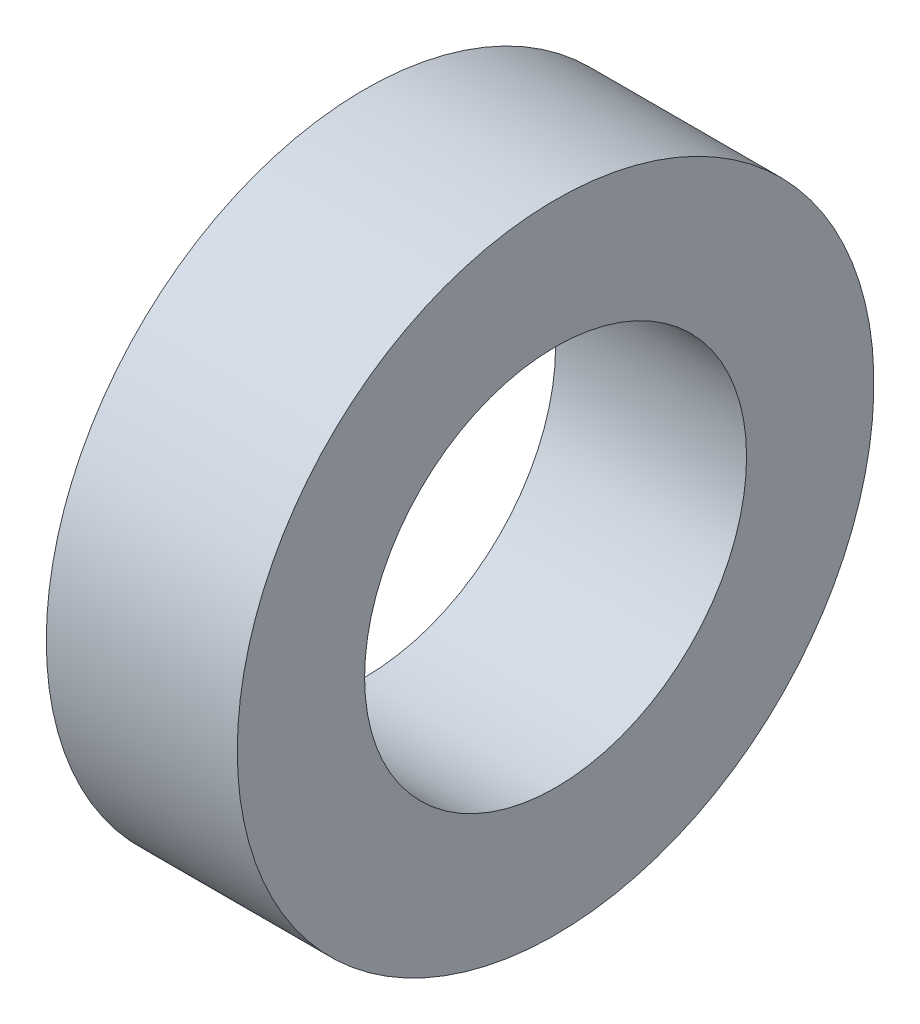
from build123d import *

# Parameters (mm, degrees)
SKETCH1_W = 3
SKETCH1_H = 2


with BuildPart() as part:
    # Sketch1 → Revolve1 (revolve)
    with BuildSketch(Plane.XY):
        with Locations((1.5, 4)):
            Rectangle(SKETCH1_W, SKETCH1_H)
    revolve(axis=Axis((0, 0, 0), (1, 0, 0)))


solid = part.part
